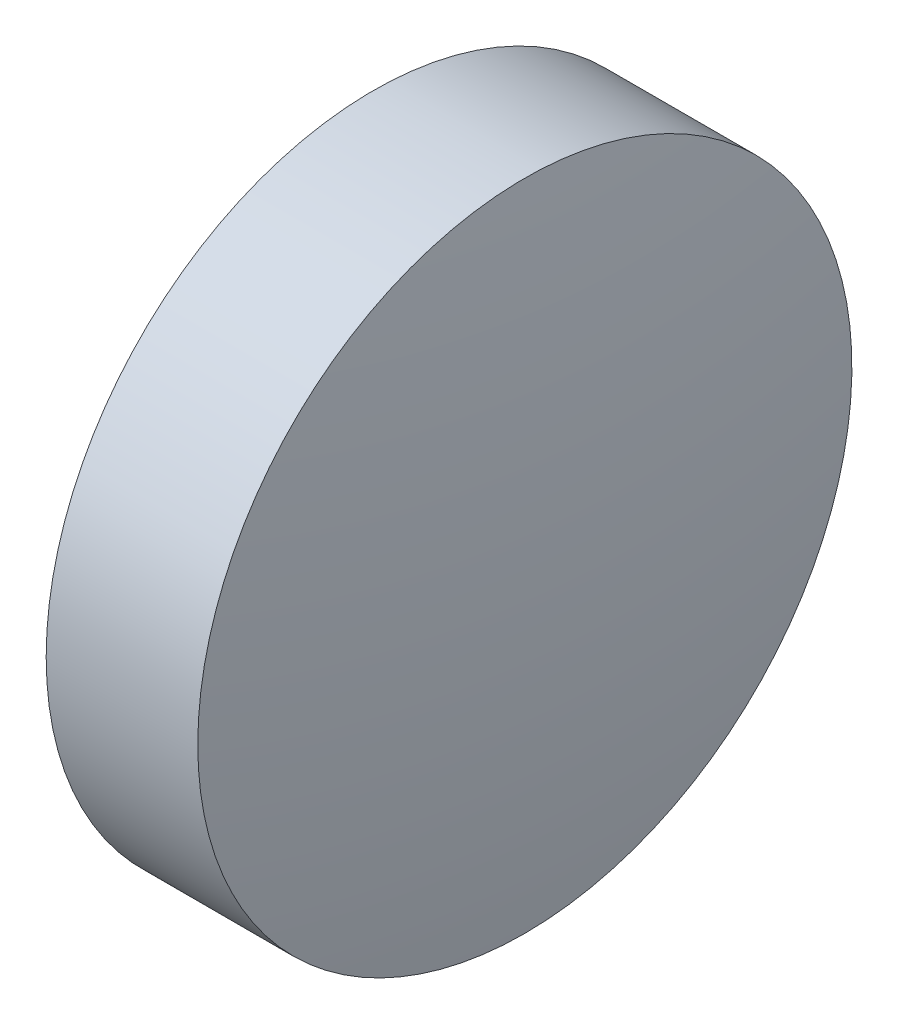
from build123d import *


with BuildPart() as part:
    # 草图1 → 旋转1 (revolve)
    with BuildSketch(Plane.XY, mode=Mode.PRIVATE) as revolve_1_sk:
        with BuildLine():
            Line((623.587402801, 93.6314284), (623.587402801, 96.7814284))
            Line((623.587402801, 96.7814284), (625.047402801, 96.7814284))
            ThreePointArc((625.047402801, 96.7814284), (625.227315978, 95.210993213), (625.287402801, 93.6314284))
            Line((625.287402801, 93.6314284), (623.587402801, 93.6314284))
        make_face()
    revolve(revolve_1_sk.sketch.rotate(Axis((622.725774631, 93.6314284, 0), (1, 0, 0)), 180), axis=Axis((622.725774631, 93.6314284, 0), (1, 0, 0)))  # turned: the seam where the file's is


solid = part.part
